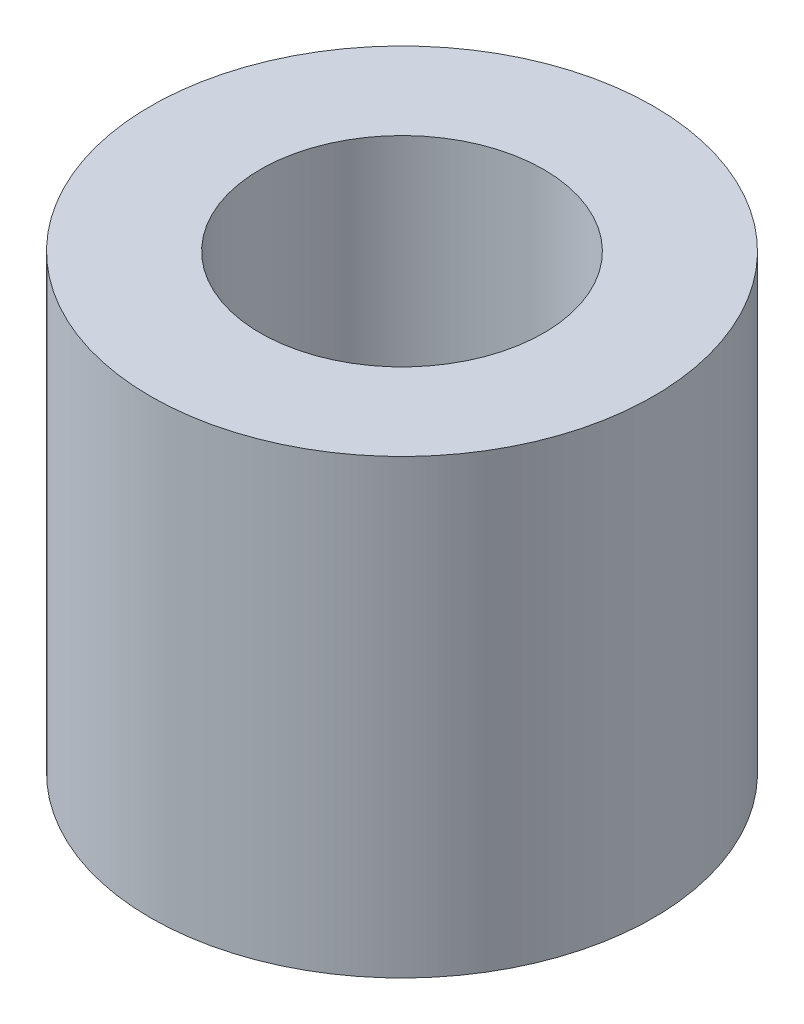
from build123d import *


with BuildPart() as part:
    # Sketch1 → Revolve1 (revolve)
    with BuildSketch(Plane.XY):
        Polygon((-3.175, 0), (-20.7264, 0), (-20.7264, 37.2364), (-11.684, 37.2364), (-11.684, 7.3914), (-3.175, 7.3914), align=None)
    revolve(axis=Axis((0, 0, 0), (0, 1, 0)))


solid = part.part
